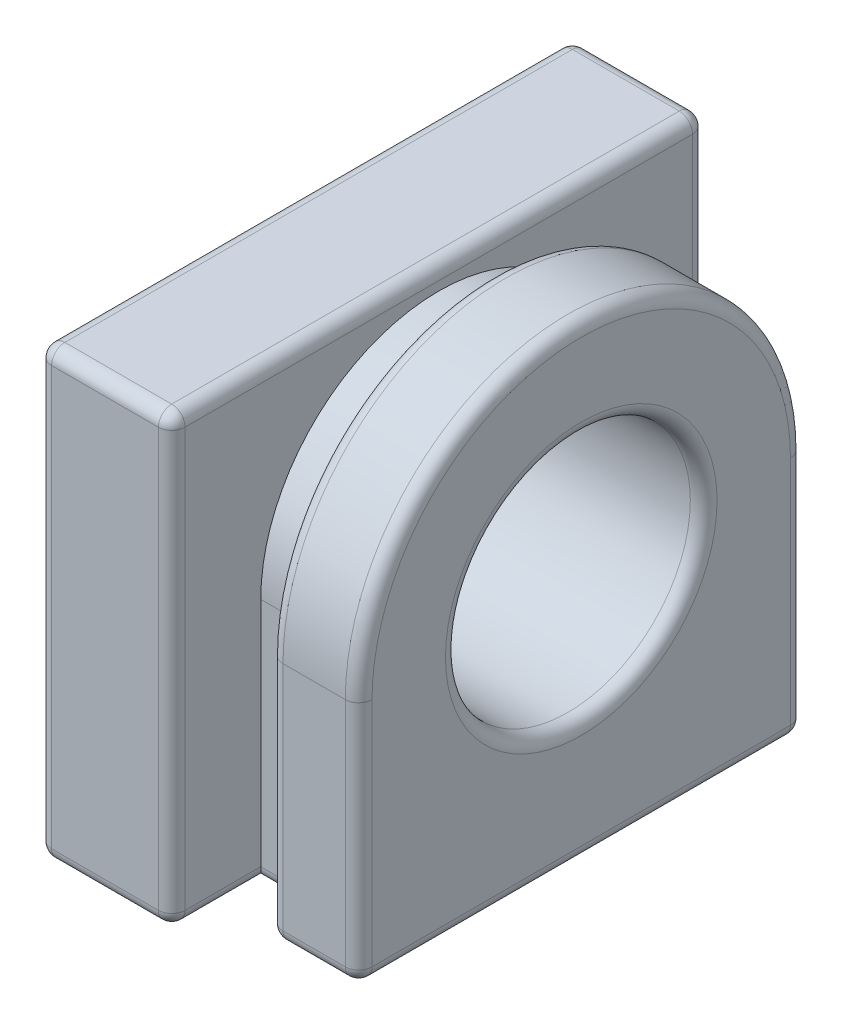
from build123d import *

# Parameters (mm, degrees)
BOSS_EXTRUDE1_DEPTH = 1.2
SKETCH2_W           = 12
SKETCH2_H           = 10
BOSS_EXTRUDE2_DEPTH = 3
BOSS_EXTRUDE3_DEPTH = 2
CUT_EXTRUDE1_REACH  = 8.2
SKETCH4_R           = 2.75
FILLET1_R           = 0.3


with BuildPart() as part:
    # Sketch1 → Boss-Extrude1 (new body)
    with BuildSketch(Plane(origin=(0, 0, 0), x_dir=(0, 0, -1), z_dir=(1, 0, 0))):
        with BuildLine():
            Line((-4, 0), (-4, -5.5))
            Line((-4, -5.5), (4, -5.5))
            Line((4, -5.5), (4, 0))
            ThreePointArc((4, 0), (0, 4), (-4, 0))
        make_face()
    extrude(amount=BOSS_EXTRUDE1_DEPTH)

    # Sketch2 → Boss-Extrude2 (add)
    with BuildSketch(Plane.ZY):
        with Locations((0, -0.5)):
            Rectangle(SKETCH2_W, SKETCH2_H)
    extrude(amount=BOSS_EXTRUDE2_DEPTH)

    # Sketch3 → Boss-Extrude3 (add)
    with BuildSketch(Plane(origin=(1.2, 0, 0), x_dir=(0, 0, -1), z_dir=(1, 0, 0))):
        with BuildLine():
            Line((-5, 0), (-5, -5.5))
            Line((-5, -5.5), (5, -5.5))
            Line((5, -5.5), (5, 0))
            ThreePointArc((5, 0), (0, 5), (-5, 0))
        make_face()
    extrude(amount=BOSS_EXTRUDE3_DEPTH)

    # Sketch4 → Cut-Extrude1 (cut, up to next)
    with BuildSketch(Plane(origin=(3.2, 0, 0), x_dir=(0, 0, -1), z_dir=(1, 0, 0)), mode=Mode.PRIVATE) as cut_extrude1_sk1:
        Circle(SKETCH4_R)
    cut_extrude1_tool1 = extrude(cut_extrude1_sk1.sketch, amount=-CUT_EXTRUDE1_REACH, mode=Mode.PRIVATE) & part.part
    add(cut_extrude1_tool1.solids().sort_by_distance((3.2, 0, 0))[0], mode=Mode.SUBTRACT)

    # Fillet1
    fillet1_edges = [part.edges().sort_by_distance(p)[0] for p in [
        (1.2, -2.75, -5),
        (1.2, -2.75, 5),
        (3.2, -2.75, -5),
        (3.2, -2.75, 5),
        (-3, 0, 2.75),
        (-3, 4.5, 0),
        (-1.5, 4.5, -6),
        (-3, -0.5, -6),
        (0, -0.5, -6),
        (0, -5.5, -5),
        (-1.5, -5.5, -6),
        (-3, -5.5, 0),
        (-3, -0.5, 6),
        (0, 4.5, 0),
        (-1.5, 4.5, 6),
        (0, -0.5, 6),
        (-1.5, -5.5, 6),
        (0, -5.5, 5),
        (0.6, -5.5, -4),
        (1.2, -5.5, -4.5),
        (0.6, -5.5, 4),
        (1.2, -5.5, 4.5),
        (2.2, -5.5, -5),
        (2.2, -5.5, 5),
        (1.2, 5, 0),
        (3.2, 0, 2.75),
        (3.2, -5.5, 0),
        (3.2, 5, 0),
    ]]
    fillet(fillet1_edges, radius=FILLET1_R)


solid = part.part
